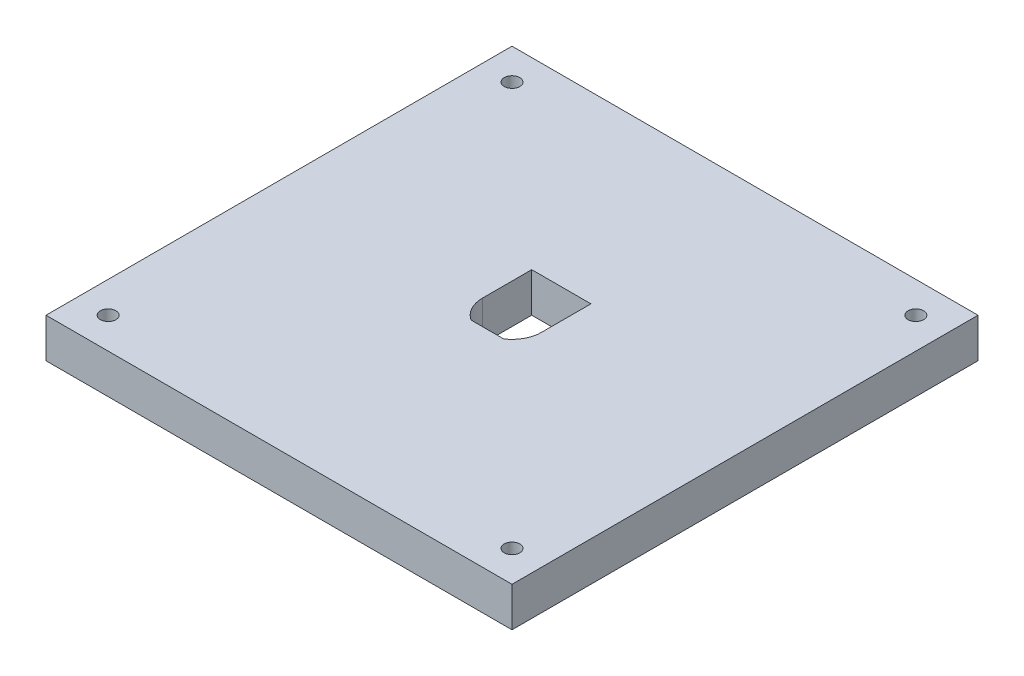
from build123d import *

# Parameters (mm, degrees)
SKETCH1_W           = 150
SKETCH1_H           = 150
BOSS_EXTRUDE1_DEPTH = 12.7
SKETCH2_W           = 10.53028371
SKETCH2_H           = 7.9375
SKETCH2_R           = 2.5
CUT_EXTRUDE1_DEPTH  = 12.7


with BuildPart() as part:
    # Sketch1 → Boss-Extrude1 (new body)
    with BuildSketch(Plane(origin=(0, 0, 0), x_dir=(1, 0, 0), z_dir=(0, 1, 0))):
        with Locations((75, 75)):
            Rectangle(SKETCH1_W, SKETCH1_H)
    extrude(amount=BOSS_EXTRUDE1_DEPTH)

    # Sketch2 → Cut-Extrude1 (cut)
    with BuildSketch(Plane(origin=(0, 12.7, 0), x_dir=(1, 0, 0), z_dir=(0, 1, 0))):
        with BuildLine():
            ThreePointArc((80.265141855, 82.9375), (83.392737967, 79.504173), (84.525, 75))
            Line((84.525, 75), (84.525, 90.875))
            Line((84.525, 90.875), (65.475, 90.875))
            Line((65.475, 90.875), (65.475, 75))
            ThreePointArc((65.475, 75), (66.607262033, 79.504173), (69.734858145, 82.9375))
            ThreePointArc((69.734858145, 82.9375), (75, 84.525), (80.265141855, 82.9375))
        make_face()
        with BuildLine():
            ThreePointArc((80.265141855, 67.0625), (83.392737967, 70.495827), (84.525, 75))
            Line((84.525, 75), (80.265141855, 75))
            Line((80.265141855, 75), (80.265141855, 67.0625))
        make_face()
        with BuildLine():
            Line((80.265141855, 75), (84.525, 75))
            ThreePointArc((84.525, 75), (83.392737967, 79.504173), (80.265141855, 82.9375))
            Line((80.265141855, 82.9375), (80.265141855, 75))
        make_face()
        with BuildLine():
            Line((69.734858145, 67.0625), (69.734858145, 75))
            Line((69.734858145, 75), (65.475, 75))
            ThreePointArc((65.475, 75), (66.607262033, 70.495827), (69.734858145, 67.0625))
        make_face()
        with BuildLine():
            Line((65.475, 75), (69.734858145, 75))
            Line((69.734858145, 75), (69.734858145, 82.9375))
            ThreePointArc((69.734858145, 82.9375), (66.607262033, 79.504173), (65.475, 75))
        make_face()
        with Locations((75, 78.96875)):
            Rectangle(SKETCH2_W, SKETCH2_H)
        with BuildLine():
            Line((69.734858145, 82.9375), (80.265141855, 82.9375))
            ThreePointArc((80.265141855, 82.9375), (75, 84.525), (69.734858145, 82.9375))
        make_face()
        with Locations((75, 71.03125)):
            Rectangle(SKETCH2_W, SKETCH2_H)
        with Locations((10, 140)):
            Circle(SKETCH2_R)
        with Locations((140, 140)):
            Circle(SKETCH2_R)
        with Locations((140, 10)):
            Circle(SKETCH2_R)
        with Locations((10, 10)):
            Circle(SKETCH2_R)
    extrude(amount=-CUT_EXTRUDE1_DEPTH, mode=Mode.SUBTRACT)


solid = part.part
